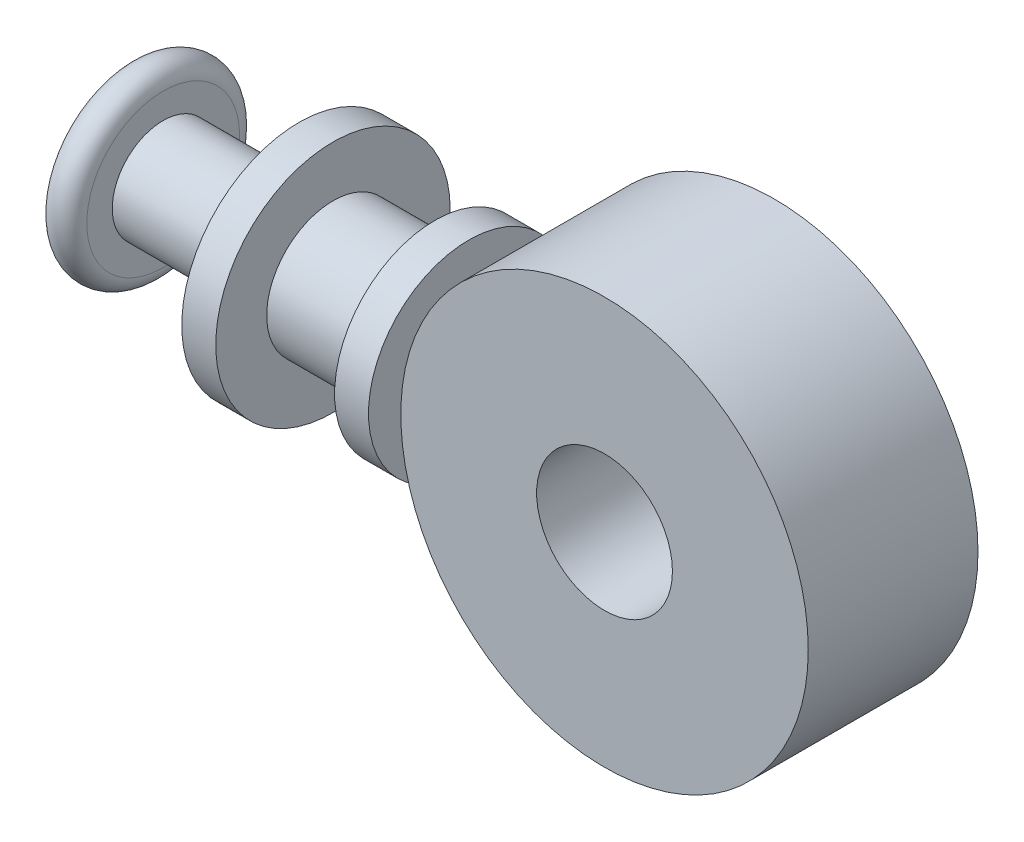
from build123d import *

# Parameters (mm, degrees)
SKETCH1_R                = 9.4107
SKETCH1_R_2              = 3.1369
BOSS_EXTRUDE1_DEPTH      = 3.92049
BOSS_EXTRUDE1_DEPTH_BACK = 3.92049


with BuildPart() as part:
    # Sketch1 → Boss-Extrude1 (new body, two sides)
    with BuildSketch(Plane.XY) as boss_extrude1_sk:
        Circle(SKETCH1_R)
        Circle(SKETCH1_R_2, mode=Mode.SUBTRACT)
    extrude(amount=BOSS_EXTRUDE1_DEPTH)
    extrude(boss_extrude1_sk.sketch, amount=-BOSS_EXTRUDE1_DEPTH_BACK)

    # Sketch2 → Revolve1 (revolve)
    with BuildSketch(Plane(origin=(0, 0, 0), x_dir=(1, 0, 0), z_dir=(0, 1, 0))):
        with BuildLine():
            Line((-5.959188984, 0), (-25.87498, 0))
            Line((-25.87498, 0), (-25.87498, 3.52933))
            ThreePointArc((-25.87498, 3.52933), (-25.09139, 4.31292), (-24.3078, 3.52933))
            Line((-24.3078, 3.52933), (-24.3078, 2.35204))
            Line((-24.3078, 2.35204), (-18.034, 2.35204))
            Line((-18.034, 2.35204), (-18.034, 5.41528))
            Line((-18.034, 5.41528), (-16.46428, 5.41528))
            Line((-16.46428, 5.41528), (-16.46428, 3.06197))
            Line((-16.46428, 3.06197), (-11.7602, 3.06197))
            Line((-11.7602, 3.06197), (-11.7602, 4.63042))
            Line((-11.7602, 4.63042), (-10.19302, 4.63042))
            Line((-10.19302, 4.63042), (-10.19302, 2.35204))
            Line((-10.19302, 2.35204), (-5.959188984, 2.35204))
            Line((-5.959188984, 2.35204), (-5.959188984, 0))
        make_face()
    revolve(axis=Axis((-5.959188984, 0, 0), (-1, 0, 0)))


solid = part.part
